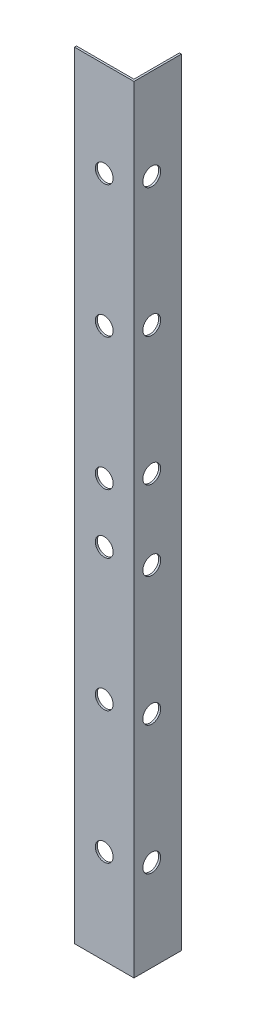
from build123d import *

# Parameters (mm, degrees)
BOSS_EXTRUDE1_DEPTH = 196
CUT_EXTRUDE4_REACH  = 17
SKETCH5_R           = 2.25
CUT_EXTRUDE5_REACH  = 14
SKETCH6_R           = 2.25


with BuildPart() as part:
    # Sketch1 → Boss-Extrude1 (new body)
    with BuildSketch(Plane(origin=(0, 0, 0), x_dir=(1, 0, 0), z_dir=(0, 1, 0))):
        Polygon((0, 0), (15, 0), (15, 12), (14.5, 12), (14.5, 0.5), (0, 0.5), align=None)
    extrude(amount=BOSS_EXTRUDE1_DEPTH)

    # Sketch5 → Cut-Extrude4 (cut, up to next)
    with BuildSketch(Plane(origin=(15, 0, 0), x_dir=(0, 0, -1), z_dir=(1, 0, 0)), mode=Mode.PRIVATE) as cut_extrude4_sk1:
        with Locations((4.5, 23)):
            Circle(SKETCH5_R)
    cut_extrude4_tool1 = extrude(cut_extrude4_sk1.sketch, amount=-CUT_EXTRUDE4_REACH, mode=Mode.PRIVATE) & part.part
    add(cut_extrude4_tool1.solids().sort_by_distance((15, 23, -4.5))[0], mode=Mode.SUBTRACT)
    # Sketch5 → Cut-Extrude4 (cut, up to next)
    with BuildSketch(Plane(origin=(15, 0, 0), x_dir=(0, 0, -1), z_dir=(1, 0, 0)), mode=Mode.PRIVATE) as cut_extrude4_sk2:
        with Locations((4.5, 55.5)):
            Circle(SKETCH5_R)
    cut_extrude4_tool2 = extrude(cut_extrude4_sk2.sketch, amount=-CUT_EXTRUDE4_REACH, mode=Mode.PRIVATE) & part.part
    add(cut_extrude4_tool2.solids().sort_by_distance((15, 55.5, -4.5))[0], mode=Mode.SUBTRACT)
    # Sketch5 → Cut-Extrude4 (cut, up to next)
    with BuildSketch(Plane(origin=(15, 0, 0), x_dir=(0, 0, -1), z_dir=(1, 0, 0)), mode=Mode.PRIVATE) as cut_extrude4_sk3:
        with Locations((4.5, 88)):
            Circle(SKETCH5_R)
    cut_extrude4_tool3 = extrude(cut_extrude4_sk3.sketch, amount=-CUT_EXTRUDE4_REACH, mode=Mode.PRIVATE) & part.part
    add(cut_extrude4_tool3.solids().sort_by_distance((15, 88, -4.5))[0], mode=Mode.SUBTRACT)
    # Sketch5 → Cut-Extrude4 (cut, up to next)
    with BuildSketch(Plane(origin=(15, 0, 0), x_dir=(0, 0, -1), z_dir=(1, 0, 0)), mode=Mode.PRIVATE) as cut_extrude4_sk4:
        with Locations((4.5, 108)):
            Circle(SKETCH5_R)
    cut_extrude4_tool4 = extrude(cut_extrude4_sk4.sketch, amount=-CUT_EXTRUDE4_REACH, mode=Mode.PRIVATE) & part.part
    add(cut_extrude4_tool4.solids().sort_by_distance((15, 108, -4.5))[0], mode=Mode.SUBTRACT)
    # Sketch5 → Cut-Extrude4 (cut, up to next)
    with BuildSketch(Plane(origin=(15, 0, 0), x_dir=(0, 0, -1), z_dir=(1, 0, 0)), mode=Mode.PRIVATE) as cut_extrude4_sk5:
        with Locations((4.5, 140.5)):
            Circle(SKETCH5_R)
    cut_extrude4_tool5 = extrude(cut_extrude4_sk5.sketch, amount=-CUT_EXTRUDE4_REACH, mode=Mode.PRIVATE) & part.part
    add(cut_extrude4_tool5.solids().sort_by_distance((15, 140.5, -4.5))[0], mode=Mode.SUBTRACT)
    # Sketch5 → Cut-Extrude4 (cut, up to next)
    with BuildSketch(Plane(origin=(15, 0, 0), x_dir=(0, 0, -1), z_dir=(1, 0, 0)), mode=Mode.PRIVATE) as cut_extrude4_sk6:
        with Locations((4.5, 173)):
            Circle(SKETCH5_R)
    cut_extrude4_tool6 = extrude(cut_extrude4_sk6.sketch, amount=-CUT_EXTRUDE4_REACH, mode=Mode.PRIVATE) & part.part
    add(cut_extrude4_tool6.solids().sort_by_distance((15, 173, -4.5))[0], mode=Mode.SUBTRACT)

    # Sketch6 → Cut-Extrude5 (cut, up to next)
    with BuildSketch(Plane.XY, mode=Mode.PRIVATE) as cut_extrude5_sk1:
        with Locations((7.5, 23.833333333)):
            Circle(SKETCH6_R)
    cut_extrude5_tool1 = extrude(cut_extrude5_sk1.sketch, amount=-CUT_EXTRUDE5_REACH, mode=Mode.PRIVATE) & part.part
    add(cut_extrude5_tool1.solids().sort_by_distance((7.5, 23.833333, 0))[0], mode=Mode.SUBTRACT)
    # Sketch6 → Cut-Extrude5 (cut, up to next)
    with BuildSketch(Plane.XY, mode=Mode.PRIVATE) as cut_extrude5_sk2:
        with Locations((7.5, 57.166666667)):
            Circle(SKETCH6_R)
    cut_extrude5_tool2 = extrude(cut_extrude5_sk2.sketch, amount=-CUT_EXTRUDE5_REACH, mode=Mode.PRIVATE) & part.part
    add(cut_extrude5_tool2.solids().sort_by_distance((7.5, 57.166667, 0))[0], mode=Mode.SUBTRACT)
    # Sketch6 → Cut-Extrude5 (cut, up to next)
    with BuildSketch(Plane.XY, mode=Mode.PRIVATE) as cut_extrude5_sk3:
        with Locations((7.5, 90.5)):
            Circle(SKETCH6_R)
    cut_extrude5_tool3 = extrude(cut_extrude5_sk3.sketch, amount=-CUT_EXTRUDE5_REACH, mode=Mode.PRIVATE) & part.part
    add(cut_extrude5_tool3.solids().sort_by_distance((7.5, 90.5, 0))[0], mode=Mode.SUBTRACT)
    # Sketch6 → Cut-Extrude5 (cut, up to next)
    with BuildSketch(Plane.XY, mode=Mode.PRIVATE) as cut_extrude5_sk4:
        with Locations((7.5, 105.5)):
            Circle(SKETCH6_R)
    cut_extrude5_tool4 = extrude(cut_extrude5_sk4.sketch, amount=-CUT_EXTRUDE5_REACH, mode=Mode.PRIVATE) & part.part
    add(cut_extrude5_tool4.solids().sort_by_distance((7.5, 105.5, 0))[0], mode=Mode.SUBTRACT)
    # Sketch6 → Cut-Extrude5 (cut, up to next)
    with BuildSketch(Plane.XY, mode=Mode.PRIVATE) as cut_extrude5_sk5:
        with Locations((7.5, 138.833333333)):
            Circle(SKETCH6_R)
    cut_extrude5_tool5 = extrude(cut_extrude5_sk5.sketch, amount=-CUT_EXTRUDE5_REACH, mode=Mode.PRIVATE) & part.part
    add(cut_extrude5_tool5.solids().sort_by_distance((7.5, 138.833333, 0))[0], mode=Mode.SUBTRACT)
    # Sketch6 → Cut-Extrude5 (cut, up to next)
    with BuildSketch(Plane.XY, mode=Mode.PRIVATE) as cut_extrude5_sk6:
        with Locations((7.5, 172.166666667)):
            Circle(SKETCH6_R)
    cut_extrude5_tool6 = extrude(cut_extrude5_sk6.sketch, amount=-CUT_EXTRUDE5_REACH, mode=Mode.PRIVATE) & part.part
    add(cut_extrude5_tool6.solids().sort_by_distance((7.5, 172.166667, 0))[0], mode=Mode.SUBTRACT)


solid = part.part
